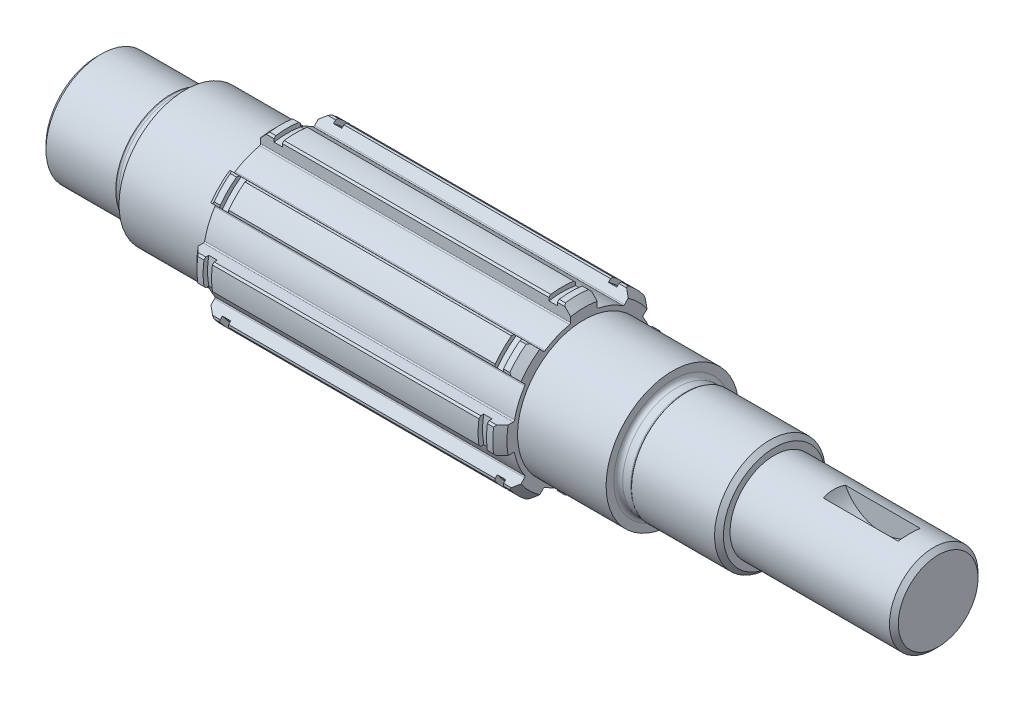
from build123d import *

# Parameters (mm, degrees)
CUT_EXTRUDE_1_REACH      = 115.234
SKETCH_3_R               = 9.5
CUT_EXTRUDE_2_DEPTH      = 2.5
CUT_EXTRUDE_2_DEPTH_BACK = 2.5


with BuildPart() as part:
    # Эскиз 1 → Повернуть1 (revolve)
    with BuildSketch(Plane.XY, mode=Mode.PRIVATE) as revolve_1_sk:
        with BuildLine():
            Line((0, 11.5), (0, 0))
            Line((0, 0), (190, 0))
            Line((190, 0), (190, 9))
            Line((190, 9), (189, 10))
            Line((189, 10), (153, 10))
            Line((153, 10), (153, 11.5))
            Line((153, 11.5), (152, 12.5))
            Line((152, 12.5), (133.25, 12.5))
            Line((133.25, 12.5), (133.146446609, 12.396446609))
            ThreePointArc((133.146446609, 12.396446609), (132.984234935, 12.288060234), (132.792893219, 12.25))
            Line((132.792893219, 12.25), (131, 12.25))
            ThreePointArc((131, 12.25), (130.292893219, 12.542893219), (130, 13.25))
            Line((130, 13.25), (130, 15))
            Line((130, 15), (110, 15))
            Line((110, 15), (110, 17.4))
            Line((110, 17.4), (108.4, 19))
            Line((108.4, 19), (107, 19))
            Line((107, 19), (107, 18))
            Line((107, 18), (105.1, 18))
            Line((105.1, 18), (105.1, 19))
            Line((105.1, 19), (44.9, 19))
            Line((44.9, 19), (44.9, 18))
            Line((44.9, 18), (43, 18))
            Line((43, 18), (43, 19))
            Line((43, 19), (41.6, 19))
            Line((41.6, 19), (40, 17.4))
            Line((40, 17.4), (40, 15))
            Line((40, 15), (20, 15))
            Line((20, 15), (20, 13.25))
            ThreePointArc((20, 13.25), (19.707106781, 12.542893219), (19, 12.25))
            Line((19, 12.25), (17.207106781, 12.25))
            ThreePointArc((17.207106781, 12.25), (17.015765065, 12.288060234), (16.853553391, 12.396446609))
            Line((16.853553391, 12.396446609), (16.75, 12.5))
            Line((16.75, 12.5), (1, 12.5))
            Line((1, 12.5), (0, 11.5))
        make_face()
    revolve(revolve_1_sk.sketch.rotate(Axis((0, 0, 0), (1, 0, 0)), 180), axis=Axis((0, 0, 0), (1, 0, 0)))

    # Вырез-Вытянуть1: up to this face of the body (flat: up to its plane)
    cut_extrude_1_end = Plane(part.part.faces().sort_by_distance((40, 16.90785368, 0))[0])
    # Эскиз2 → Вырез-Вытянуть1 (cut, up to the picked face)
    with BuildSketch(Plane(origin=(110, 0, 0), x_dir=(0, 0, -1), z_dir=(1, 0, 0)), mode=Mode.PRIVATE) as cut_extrude_1_sk1:
        with BuildLine():
            Line((-3, 17.139428229), (-3, 18.42126457))
            Line((-3, 18.42126457), (-2.6, 18.82126457))
            ThreePointArc((-2.6, 18.82126457), (-7.270985215, 17.553711118), (-11.470166177, 15.147121439))
            Line((-11.470166177, 15.147121439), (-10.904480752, 15.147121439))
            Line((-10.904480752, 15.147121439), (-9.998085582, 14.24072627))
            ThreePointArc((-9.998085582, 14.24072627), (-6.658691723, 16.075503866), (-3, 17.139428229))
        make_face()
    cut_extrude_1_tool1 = split(extrude(cut_extrude_1_sk1.sketch, amount=-CUT_EXTRUDE_1_REACH, mode=Mode.PRIVATE), bisect_by=cut_extrude_1_end, keep=Keep.BOTH, mode=Mode.PRIVATE)
    # Эскиз2 → Вырез-Вытянуть1 (cut, up to the picked face)
    with BuildSketch(Plane(origin=(110, 0, 0), x_dir=(0, 0, -1), z_dir=(1, 0, 0)), mode=Mode.PRIVATE) as cut_extrude_1_sk2:
        with BuildLine():
            Line((-3, 15.962455951), (-3, 17.139428229))
            ThreePointArc((-3, 17.139428229), (-6.658691723, 16.075503866), (-9.998085582, 14.24072627))
            Line((-9.998085582, 14.24072627), (-9.165840504, 13.408481191))
            ThreePointArc((-9.165840504, 13.408481191), (-8.984235017, 13.322170384), (-8.788916289, 13.369927093))
            ThreePointArc((-8.788916289, 13.369927093), (-6.122934918, 14.78207252), (-3.239263804, 15.668668419))
            ThreePointArc((-3.239263804, 15.668668419), (-3.067383514, 15.773010522), (-3, 15.962455951))
        make_face()
    cut_extrude_1_tool2 = split(extrude(cut_extrude_1_sk2.sketch, amount=-CUT_EXTRUDE_1_REACH, mode=Mode.PRIVATE), bisect_by=cut_extrude_1_end, keep=Keep.BOTH, mode=Mode.PRIVATE)
    # Эскиз2 → Вырез-Вытянуть1 (cut, up to the picked face)
    with BuildSketch(Plane(origin=(110, 0, 0), x_dir=(0, 0, -1), z_dir=(1, 0, 0)), mode=Mode.PRIVATE) as cut_extrude_1_sk3:
        with BuildLine():
            Line((-15.147121439, 10.904480752), (-15.147121439, 11.470166177))
            ThreePointArc((-15.147121439, 11.470166177), (-17.553711118, 7.270985215), (-18.82126457, 2.6))
            Line((-18.82126457, 2.6), (-18.42126457, 3))
            Line((-18.42126457, 3), (-17.139428229, 3))
            ThreePointArc((-17.139428229, 3), (-16.075503866, 6.658691723), (-14.24072627, 9.998085582))
            Line((-14.24072627, 9.998085582), (-15.147121439, 10.904480752))
        make_face()
    cut_extrude_1_tool3 = split(extrude(cut_extrude_1_sk3.sketch, amount=-CUT_EXTRUDE_1_REACH, mode=Mode.PRIVATE), bisect_by=cut_extrude_1_end, keep=Keep.BOTH, mode=Mode.PRIVATE)
    # Эскиз2 → Вырез-Вытянуть1 (cut, up to the picked face)
    with BuildSketch(Plane(origin=(110, 0, 0), x_dir=(0, 0, -1), z_dir=(1, 0, 0)), mode=Mode.PRIVATE) as cut_extrude_1_sk4:
        with BuildLine():
            Line((-13.408481191, 9.165840504), (-14.24072627, 9.998085582))
            ThreePointArc((-14.24072627, 9.998085582), (-16.075503866, 6.658691723), (-17.139428229, 3))
            Line((-17.139428229, 3), (-15.962455951, 3))
            ThreePointArc((-15.962455951, 3), (-15.773010522, 3.067383514), (-15.668668419, 3.239263804))
            ThreePointArc((-15.668668419, 3.239263804), (-14.78207252, 6.122934918), (-13.369927093, 8.788916289))
            ThreePointArc((-13.369927093, 8.788916289), (-13.322170384, 8.984235017), (-13.408481191, 9.165840504))
        make_face()
    cut_extrude_1_tool4 = split(extrude(cut_extrude_1_sk4.sketch, amount=-CUT_EXTRUDE_1_REACH, mode=Mode.PRIVATE), bisect_by=cut_extrude_1_end, keep=Keep.BOTH, mode=Mode.PRIVATE)
    # Эскиз2 → Вырез-Вытянуть1 (cut, up to the picked face)
    with BuildSketch(Plane(origin=(110, 0, 0), x_dir=(0, 0, -1), z_dir=(1, 0, 0)), mode=Mode.PRIVATE) as cut_extrude_1_sk5:
        with BuildLine():
            Line((-18.42126457, -3), (-18.82126457, -2.6))
            ThreePointArc((-18.82126457, -2.6), (-17.553711118, -7.270985215), (-15.147121439, -11.470166177))
            Line((-15.147121439, -11.470166177), (-15.147121439, -10.904480752))
            Line((-15.147121439, -10.904480752), (-14.24072627, -9.998085582))
            ThreePointArc((-14.24072627, -9.998085582), (-16.075503866, -6.658691723), (-17.139428229, -3))
            Line((-17.139428229, -3), (-18.42126457, -3))
        make_face()
    cut_extrude_1_tool5 = split(extrude(cut_extrude_1_sk5.sketch, amount=-CUT_EXTRUDE_1_REACH, mode=Mode.PRIVATE), bisect_by=cut_extrude_1_end, keep=Keep.BOTH, mode=Mode.PRIVATE)
    # Эскиз2 → Вырез-Вытянуть1 (cut, up to the picked face)
    with BuildSketch(Plane(origin=(110, 0, 0), x_dir=(0, 0, -1), z_dir=(1, 0, 0)), mode=Mode.PRIVATE) as cut_extrude_1_sk6:
        with BuildLine():
            Line((-15.962455951, -3), (-17.139428229, -3))
            ThreePointArc((-17.139428229, -3), (-16.075503866, -6.658691723), (-14.24072627, -9.998085582))
            Line((-14.24072627, -9.998085582), (-13.408481191, -9.165840504))
            ThreePointArc((-13.408481191, -9.165840504), (-13.322170384, -8.984235017), (-13.369927093, -8.788916289))
            ThreePointArc((-13.369927093, -8.788916289), (-14.78207252, -6.122934918), (-15.668668419, -3.239263804))
            ThreePointArc((-15.668668419, -3.239263804), (-15.773010522, -3.067383514), (-15.962455951, -3))
        make_face()
    cut_extrude_1_tool6 = split(extrude(cut_extrude_1_sk6.sketch, amount=-CUT_EXTRUDE_1_REACH, mode=Mode.PRIVATE), bisect_by=cut_extrude_1_end, keep=Keep.BOTH, mode=Mode.PRIVATE)
    # Эскиз2 → Вырез-Вытянуть1 (cut, up to the picked face)
    with BuildSketch(Plane(origin=(110, 0, 0), x_dir=(0, 0, -1), z_dir=(1, 0, 0)), mode=Mode.PRIVATE) as cut_extrude_1_sk7:
        with BuildLine():
            Line((-9.165840504, -13.408481191), (-9.998085582, -14.24072627))
            ThreePointArc((-9.998085582, -14.24072627), (-6.658691723, -16.075503866), (-3, -17.139428229))
            Line((-3, -17.139428229), (-3, -15.962455951))
            ThreePointArc((-3, -15.962455951), (-3.067383514, -15.773010522), (-3.239263804, -15.668668419))
            ThreePointArc((-3.239263804, -15.668668419), (-6.122934918, -14.78207252), (-8.788916289, -13.369927093))
            ThreePointArc((-8.788916289, -13.369927093), (-8.984235017, -13.322170384), (-9.165840504, -13.408481191))
        make_face()
    cut_extrude_1_tool7 = split(extrude(cut_extrude_1_sk7.sketch, amount=-CUT_EXTRUDE_1_REACH, mode=Mode.PRIVATE), bisect_by=cut_extrude_1_end, keep=Keep.BOTH, mode=Mode.PRIVATE)
    # Эскиз2 → Вырез-Вытянуть1 (cut, up to the picked face)
    with BuildSketch(Plane(origin=(110, 0, 0), x_dir=(0, 0, -1), z_dir=(1, 0, 0)), mode=Mode.PRIVATE) as cut_extrude_1_sk8:
        with BuildLine():
            Line((-10.904480752, -15.147121439), (-11.470166177, -15.147121439))
            ThreePointArc((-11.470166177, -15.147121439), (-7.270985215, -17.553711118), (-2.6, -18.82126457))
            Line((-2.6, -18.82126457), (-3, -18.42126457))
            Line((-3, -18.42126457), (-3, -17.139428229))
            ThreePointArc((-3, -17.139428229), (-6.658691723, -16.075503866), (-9.998085582, -14.24072627))
            Line((-9.998085582, -14.24072627), (-10.904480752, -15.147121439))
        make_face()
    cut_extrude_1_tool8 = split(extrude(cut_extrude_1_sk8.sketch, amount=-CUT_EXTRUDE_1_REACH, mode=Mode.PRIVATE), bisect_by=cut_extrude_1_end, keep=Keep.BOTH, mode=Mode.PRIVATE)
    # Эскиз2 → Вырез-Вытянуть1 (cut, up to the picked face)
    with BuildSketch(Plane(origin=(110, 0, 0), x_dir=(0, 0, -1), z_dir=(1, 0, 0)), mode=Mode.PRIVATE) as cut_extrude_1_sk9:
        with BuildLine():
            ThreePointArc((3, -17.139428229), (6.658691723, -16.075503866), (9.998085582, -14.24072627))
            Line((9.998085582, -14.24072627), (9.165840504, -13.408481191))
            ThreePointArc((9.165840504, -13.408481191), (8.984235017, -13.322170384), (8.788916289, -13.369927093))
            ThreePointArc((8.788916289, -13.369927093), (6.122934918, -14.78207252), (3.239263804, -15.668668419))
            ThreePointArc((3.239263804, -15.668668419), (3.067383514, -15.773010522), (3, -15.962455951))
            Line((3, -15.962455951), (3, -17.139428229))
        make_face()
    cut_extrude_1_tool9 = split(extrude(cut_extrude_1_sk9.sketch, amount=-CUT_EXTRUDE_1_REACH, mode=Mode.PRIVATE), bisect_by=cut_extrude_1_end, keep=Keep.BOTH, mode=Mode.PRIVATE)
    # Эскиз2 → Вырез-Вытянуть1 (cut, up to the picked face)
    with BuildSketch(Plane(origin=(110, 0, 0), x_dir=(0, 0, -1), z_dir=(1, 0, 0)), mode=Mode.PRIVATE) as cut_extrude_1_sk10:
        with BuildLine():
            ThreePointArc((2.6, -18.82126457), (7.270985215, -17.553711118), (11.470166177, -15.147121439))
            Line((11.470166177, -15.147121439), (10.904480752, -15.147121439))
            Line((10.904480752, -15.147121439), (9.998085582, -14.24072627))
            ThreePointArc((9.998085582, -14.24072627), (6.658691723, -16.075503866), (3, -17.139428229))
            Line((3, -17.139428229), (3, -18.42126457))
            Line((3, -18.42126457), (2.6, -18.82126457))
        make_face()
    cut_extrude_1_tool10 = split(extrude(cut_extrude_1_sk10.sketch, amount=-CUT_EXTRUDE_1_REACH, mode=Mode.PRIVATE), bisect_by=cut_extrude_1_end, keep=Keep.BOTH, mode=Mode.PRIVATE)
    # Эскиз2 → Вырез-Вытянуть1 (cut, up to the picked face)
    with BuildSketch(Plane(origin=(110, 0, 0), x_dir=(0, 0, -1), z_dir=(1, 0, 0)), mode=Mode.PRIVATE) as cut_extrude_1_sk11:
        with BuildLine():
            ThreePointArc((11.470166177, 15.147121439), (7.270985215, 17.553711118), (2.6, 18.82126457))
            Line((2.6, 18.82126457), (3, 18.42126457))
            Line((3, 18.42126457), (3, 17.139428229))
            ThreePointArc((3, 17.139428229), (6.658691723, 16.075503866), (9.998085582, 14.24072627))
            Line((9.998085582, 14.24072627), (10.904480752, 15.147121439))
            Line((10.904480752, 15.147121439), (11.470166177, 15.147121439))
        make_face()
    cut_extrude_1_tool11 = split(extrude(cut_extrude_1_sk11.sketch, amount=-CUT_EXTRUDE_1_REACH, mode=Mode.PRIVATE), bisect_by=cut_extrude_1_end, keep=Keep.BOTH, mode=Mode.PRIVATE)
    # Эскиз2 → Вырез-Вытянуть1 (cut, up to the picked face)
    with BuildSketch(Plane(origin=(110, 0, 0), x_dir=(0, 0, -1), z_dir=(1, 0, 0)), mode=Mode.PRIVATE) as cut_extrude_1_sk12:
        with BuildLine():
            ThreePointArc((9.998085582, 14.24072627), (6.658691723, 16.075503866), (3, 17.139428229))
            Line((3, 17.139428229), (3, 15.962455951))
            ThreePointArc((3, 15.962455951), (3.067383514, 15.773010522), (3.239263804, 15.668668419))
            ThreePointArc((3.239263804, 15.668668419), (6.122934918, 14.78207252), (8.788916289, 13.369927093))
            ThreePointArc((8.788916289, 13.369927093), (8.984235017, 13.322170384), (9.165840504, 13.408481191))
            Line((9.165840504, 13.408481191), (9.998085582, 14.24072627))
        make_face()
    cut_extrude_1_tool12 = split(extrude(cut_extrude_1_sk12.sketch, amount=-CUT_EXTRUDE_1_REACH, mode=Mode.PRIVATE), bisect_by=cut_extrude_1_end, keep=Keep.BOTH, mode=Mode.PRIVATE)
    # Эскиз2 → Вырез-Вытянуть1 (cut, up to the picked face)
    with BuildSketch(Plane(origin=(110, 0, 0), x_dir=(0, 0, -1), z_dir=(1, 0, 0)), mode=Mode.PRIVATE) as cut_extrude_1_sk13:
        with BuildLine():
            ThreePointArc((18.82126457, 2.6), (17.553711118, 7.270985215), (15.147121439, 11.470166177))
            Line((15.147121439, 11.470166177), (15.147121439, 10.904480752))
            Line((15.147121439, 10.904480752), (14.24072627, 9.998085582))
            ThreePointArc((14.24072627, 9.998085582), (16.075503866, 6.658691723), (17.139428229, 3))
            Line((17.139428229, 3), (18.42126457, 3))
            Line((18.42126457, 3), (18.82126457, 2.6))
        make_face()
    cut_extrude_1_tool13 = split(extrude(cut_extrude_1_sk13.sketch, amount=-CUT_EXTRUDE_1_REACH, mode=Mode.PRIVATE), bisect_by=cut_extrude_1_end, keep=Keep.BOTH, mode=Mode.PRIVATE)
    # Эскиз2 → Вырез-Вытянуть1 (cut, up to the picked face)
    with BuildSketch(Plane(origin=(110, 0, 0), x_dir=(0, 0, -1), z_dir=(1, 0, 0)), mode=Mode.PRIVATE) as cut_extrude_1_sk14:
        with BuildLine():
            ThreePointArc((17.139428229, 3), (16.075503866, 6.658691723), (14.24072627, 9.998085582))
            Line((14.24072627, 9.998085582), (13.408481191, 9.165840504))
            ThreePointArc((13.408481191, 9.165840504), (13.322170384, 8.984235017), (13.369927093, 8.788916289))
            ThreePointArc((13.369927093, 8.788916289), (14.78207252, 6.122934918), (15.668668419, 3.239263804))
            ThreePointArc((15.668668419, 3.239263804), (15.773010522, 3.067383514), (15.962455951, 3))
            Line((15.962455951, 3), (17.139428229, 3))
        make_face()
    cut_extrude_1_tool14 = split(extrude(cut_extrude_1_sk14.sketch, amount=-CUT_EXTRUDE_1_REACH, mode=Mode.PRIVATE), bisect_by=cut_extrude_1_end, keep=Keep.BOTH, mode=Mode.PRIVATE)
    # Эскиз2 → Вырез-Вытянуть1 (cut, up to the picked face)
    with BuildSketch(Plane(origin=(110, 0, 0), x_dir=(0, 0, -1), z_dir=(1, 0, 0)), mode=Mode.PRIVATE) as cut_extrude_1_sk15:
        with BuildLine():
            ThreePointArc((15.147121439, -11.470166177), (17.553711118, -7.270985215), (18.82126457, -2.6))
            Line((18.82126457, -2.6), (18.42126457, -3))
            Line((18.42126457, -3), (17.139428229, -3))
            ThreePointArc((17.139428229, -3), (16.075503866, -6.658691723), (14.24072627, -9.998085582))
            Line((14.24072627, -9.998085582), (15.147121439, -10.904480752))
            Line((15.147121439, -10.904480752), (15.147121439, -11.470166177))
        make_face()
    cut_extrude_1_tool15 = split(extrude(cut_extrude_1_sk15.sketch, amount=-CUT_EXTRUDE_1_REACH, mode=Mode.PRIVATE), bisect_by=cut_extrude_1_end, keep=Keep.BOTH, mode=Mode.PRIVATE)
    # Эскиз2 → Вырез-Вытянуть1 (cut, up to the picked face)
    with BuildSketch(Plane(origin=(110, 0, 0), x_dir=(0, 0, -1), z_dir=(1, 0, 0)), mode=Mode.PRIVATE) as cut_extrude_1_sk16:
        with BuildLine():
            ThreePointArc((14.24072627, -9.998085582), (16.075503866, -6.658691723), (17.139428229, -3))
            Line((17.139428229, -3), (15.962455951, -3))
            ThreePointArc((15.962455951, -3), (15.773010522, -3.067383514), (15.668668419, -3.239263804))
            ThreePointArc((15.668668419, -3.239263804), (14.78207252, -6.122934918), (13.369927093, -8.788916289))
            ThreePointArc((13.369927093, -8.788916289), (13.322170384, -8.984235017), (13.408481191, -9.165840504))
            Line((13.408481191, -9.165840504), (14.24072627, -9.998085582))
        make_face()
    cut_extrude_1_tool16 = split(extrude(cut_extrude_1_sk16.sketch, amount=-CUT_EXTRUDE_1_REACH, mode=Mode.PRIVATE), bisect_by=cut_extrude_1_end, keep=Keep.BOTH, mode=Mode.PRIVATE)
    add(cut_extrude_1_tool1.solids().sort_by(Axis((110, 16.691442, 6.913821), (-1, 0, 0)))[0], mode=Mode.SUBTRACT)
    add(cut_extrude_1_tool2.solids().sort_by(Axis((110, 15.331746, 6.350617), (-1, 0, 0)))[0], mode=Mode.SUBTRACT)
    add(cut_extrude_1_tool3.solids().sort_by(Axis((110, 6.913821, 16.691442), (-1, 0, 0)))[0], mode=Mode.SUBTRACT)
    add(cut_extrude_1_tool4.solids().sort_by(Axis((110, 6.350617, 15.331746), (-1, 0, 0)))[0], mode=Mode.SUBTRACT)
    add(cut_extrude_1_tool5.solids().sort_by(Axis((110, -6.913821, 16.691442), (-1, 0, 0)))[0], mode=Mode.SUBTRACT)
    add(cut_extrude_1_tool6.solids().sort_by(Axis((110, -6.350617, 15.331746), (-1, 0, 0)))[0], mode=Mode.SUBTRACT)
    add(cut_extrude_1_tool7.solids().sort_by(Axis((110, -15.331746, 6.350617), (-1, 0, 0)))[0], mode=Mode.SUBTRACT)
    add(cut_extrude_1_tool8.solids().sort_by(Axis((110, -16.691442, 6.913821), (-1, 0, 0)))[0], mode=Mode.SUBTRACT)
    add(cut_extrude_1_tool9.solids().sort_by(Axis((110, -15.331746, -6.350617), (-1, 0, 0)))[0], mode=Mode.SUBTRACT)
    add(cut_extrude_1_tool10.solids().sort_by(Axis((110, -16.691442, -6.913821), (-1, 0, 0)))[0], mode=Mode.SUBTRACT)
    add(cut_extrude_1_tool11.solids().sort_by(Axis((110, 16.691442, -6.913821), (-1, 0, 0)))[0], mode=Mode.SUBTRACT)
    add(cut_extrude_1_tool12.solids().sort_by(Axis((110, 15.331746, -6.350617), (-1, 0, 0)))[0], mode=Mode.SUBTRACT)
    add(cut_extrude_1_tool13.solids().sort_by(Axis((110, 6.913821, -16.691442), (-1, 0, 0)))[0], mode=Mode.SUBTRACT)
    add(cut_extrude_1_tool14.solids().sort_by(Axis((110, 6.350617, -15.331746), (-1, 0, 0)))[0], mode=Mode.SUBTRACT)
    add(cut_extrude_1_tool15.solids().sort_by(Axis((110, -6.913821, -16.691442), (-1, 0, 0)))[0], mode=Mode.SUBTRACT)
    add(cut_extrude_1_tool16.solids().sort_by(Axis((110, -6.350617, -15.331746), (-1, 0, 0)))[0], mode=Mode.SUBTRACT)

    # Эскиз3 → Вырез-Вытянуть2 (cut, two sides)
    with BuildSketch(Plane.XY) as cut_extrude_2_sk:
        with Locations((175, 14)):
            Circle(SKETCH_3_R)
    extrude(amount=CUT_EXTRUDE_2_DEPTH, mode=Mode.SUBTRACT)
    extrude(cut_extrude_2_sk.sketch, amount=-CUT_EXTRUDE_2_DEPTH_BACK, mode=Mode.SUBTRACT)


solid = part.part
